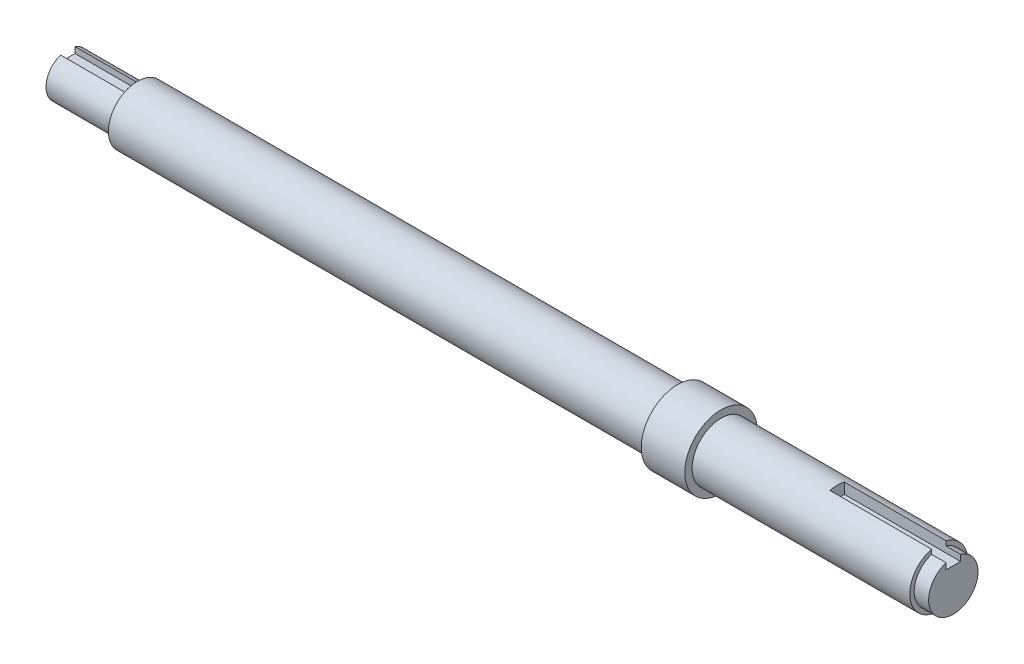
from build123d import *

# Parameters (mm, degrees)
SKETCH1_R           = 10
BOSS_EXTRUDE1_DEPTH = 300
SKETCH2_R           = 8.5
BOSS_EXTRUDE2_DEPTH = 5
SKETCH6_R           = 10
CUT_EXTRUDE2_DEPTH  = 24
SKETCH7_W           = 5
SKETCH7_H           = 5
CUT_EXTRUDE3_DEPTH  = 40
SKETCH10_R          = 12.5
BOSS_EXTRUDE4_DEPTH = 15


with BuildPart() as part:
    # Sketch1 → Boss-Extrude1 (new body)
    with BuildSketch(Plane(origin=(0, 0, 0), x_dir=(0, 0, -1), z_dir=(1, 0, 0))):
        Circle(SKETCH1_R)
    extrude(amount=BOSS_EXTRUDE1_DEPTH)

    # Sketch2 → Boss-Extrude2 (add)
    with BuildSketch(Plane(origin=(300, 0, 0), x_dir=(0, 0, -1), z_dir=(1, 0, 0))):
        Circle(SKETCH2_R)
    extrude(amount=BOSS_EXTRUDE2_DEPTH)

    # Sketch6 → Cut-Extrude2 (cut)
    with BuildSketch(Plane.ZY):
        Circle(SKETCH6_R)
        with BuildLine():
            Line((-2.5, 7.071067812), (-2.5, 5))
            Line((-2.5, 5), (2.5, 5))
            Line((2.5, 5), (2.5, 7.071067812))
            ThreePointArc((2.5, 7.071067812), (0, -7.5), (-2.5, 7.071067812))
        make_face(mode=Mode.SUBTRACT)
    extrude(amount=-CUT_EXTRUDE2_DEPTH, mode=Mode.SUBTRACT)

    # Sketch7 → Cut-Extrude3 (cut)
    with BuildSketch(Plane(origin=(305, 0, 0), x_dir=(0, 0, -1), z_dir=(1, 0, 0))):
        with Locations((0, 8.5)):
            Rectangle(SKETCH7_W, SKETCH7_H)
    extrude(amount=-CUT_EXTRUDE3_DEPTH, mode=Mode.SUBTRACT)

    # Sketch10 → Boss-Extrude4 (add)
    with BuildSketch(Plane(origin=(225, 0, 0), x_dir=(0, 0, -1), z_dir=(1, 0, 0))):
        Circle(SKETCH10_R)
    extrude(amount=-BOSS_EXTRUDE4_DEPTH)


solid = part.part
